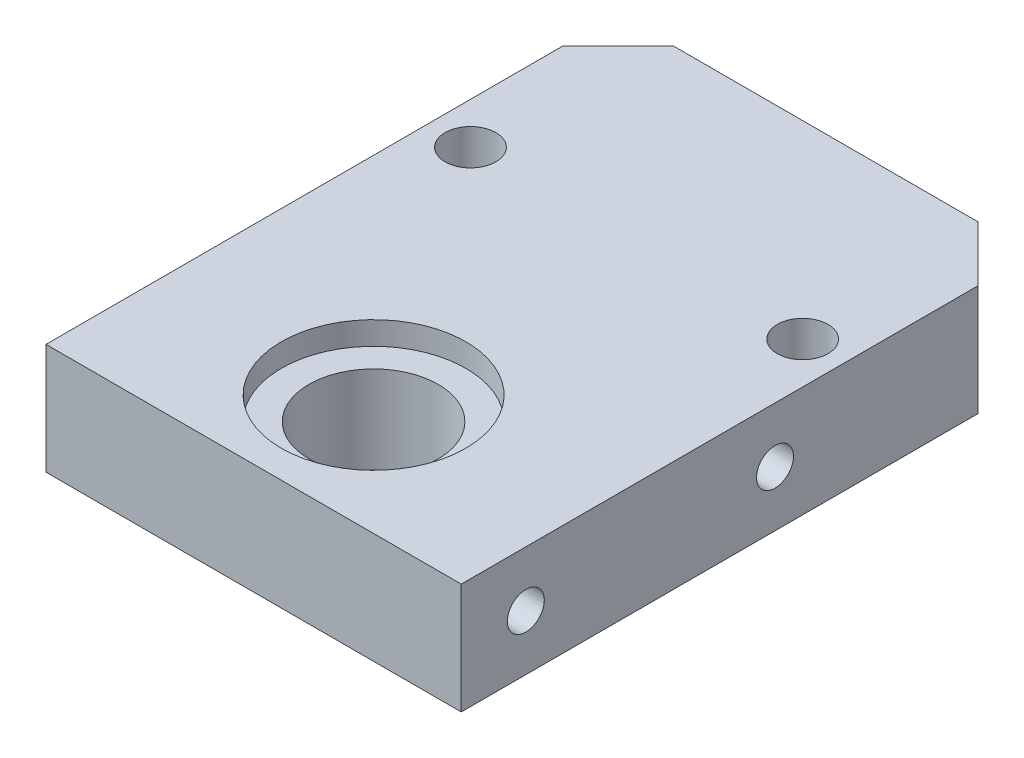
from build123d import *

# Parameters (mm, degrees)
SKETCH1_W           = 45
SKETCH1_H           = 62
BOSS_EXTRUDE1_DEPTH = 12
SKETCH2_R           = 7
SKETCH2_R_2         = 2.75
CUT_EXTRUDE1_DEPTH  = 12
SKETCH3_R           = 10
CUT_EXTRUDE2_DEPTH  = 2.5
SKETCH4_R           = 2
CUT_EXTRUDE3_DEPTH  = 16
SKETCH5_R           = 2
CUT_EXTRUDE4_DEPTH  = 16
CHAMFER1_SIZE       = 6


with BuildPart() as part:
    # Sketch1 → Boss-Extrude1 (new body)
    with BuildSketch(Plane(origin=(0, 0, 0), x_dir=(1, 0, 0), z_dir=(0, 1, 0))):
        Rectangle(SKETCH1_W, SKETCH1_H)
    extrude(amount=BOSS_EXTRUDE1_DEPTH)

    # Sketch2 → Cut-Extrude1 (cut)
    with BuildSketch(Plane(origin=(0, 12, 0), x_dir=(1, 0, 0), z_dir=(0, 1, 0))):
        with Locations((0, -18)):
            Circle(SKETCH2_R)
        with Locations((-18, 10.5)):
            Circle(SKETCH2_R_2)
        with Locations((18, 10.5)):
            Circle(SKETCH2_R_2)
    extrude(amount=-CUT_EXTRUDE1_DEPTH, mode=Mode.SUBTRACT)

    # Sketch3 → Cut-Extrude2 (cut)
    with BuildSketch(Plane(origin=(0, 12, 0), x_dir=(1, 0, 0), z_dir=(0, 1, 0))):
        with Locations((0, -18)):
            Circle(SKETCH3_R)
    extrude(amount=-CUT_EXTRUDE2_DEPTH, mode=Mode.SUBTRACT)

    # Sketch4 → Cut-Extrude3 (cut)
    with BuildSketch(Plane.ZY.offset(22.5)):
        with Locations((24, 6)):
            Circle(SKETCH4_R)
        with Locations((-3, 6)):
            Circle(SKETCH4_R)
    extrude(amount=-CUT_EXTRUDE3_DEPTH, mode=Mode.SUBTRACT)

    # Sketch5 → Cut-Extrude4 (cut)
    with BuildSketch(Plane(origin=(22.5, 0, 0), x_dir=(0, 0, -1), z_dir=(1, 0, 0))):
        with Locations((-24, 6)):
            Circle(SKETCH5_R)
        with Locations((3, 6)):
            Circle(SKETCH5_R)
    extrude(amount=-CUT_EXTRUDE4_DEPTH, mode=Mode.SUBTRACT)

    # Chamfer1
    chamfer1_edges = [part.edges().sort_by_distance(p)[0] for p in [
        (-22.5, 6, -31),
        (22.5, 6, -31),
    ]]
    chamfer(chamfer1_edges, length=CHAMFER1_SIZE)


solid = part.part
